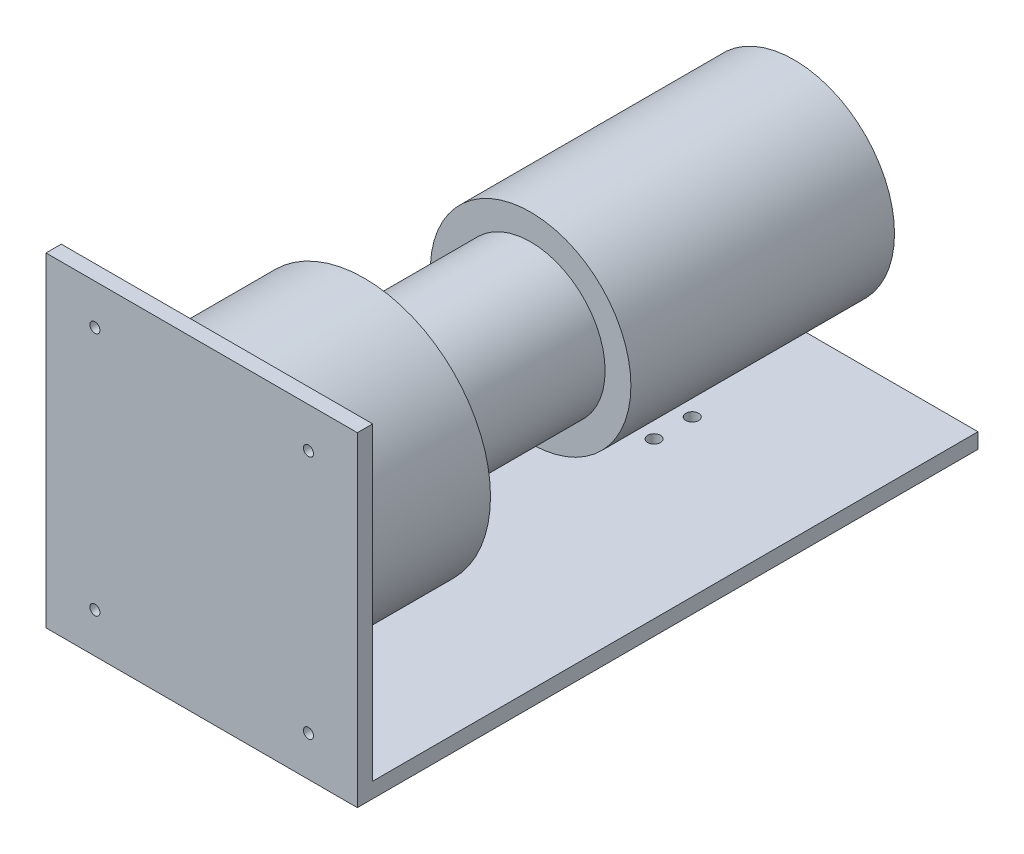
from build123d import *

# Parameters (mm, degrees)
CROQUIS1_R              = 66
SALIENTE_EXTRUIR1_DEPTH = 80
CROQUIS2_R              = 39
SALIENTE_EXTRUIR2_DEPTH = 87
CROQUIS4_R              = 52.5
SALIENTE_EXTRUIR3_DEPTH = 138
SALIENTE_EXTRUIR4_DEPTH = 81.5
CROQUIS6_R              = 2.625
CORTAR_EXTRUIR1_DEPTH   = 81.5
SKETCH1_R               = 3.35
CUT_EXTRUDE1_DEPTH      = 8


with BuildPart() as part:
    # Croquis1 → Saliente-Extruir1 (new body)
    with BuildSketch(Plane.XY):
        Circle(CROQUIS1_R)
    extrude(amount=SALIENTE_EXTRUIR1_DEPTH)

    # Croquis2 → Saliente-Extruir2 (add)
    with BuildSketch(Plane.XY):
        Circle(CROQUIS2_R)
    extrude(amount=-SALIENTE_EXTRUIR2_DEPTH)

    # Croquis4 → Saliente-Extruir3 (add)
    with BuildSketch(Plane.XY.offset(-87)):
        Circle(CROQUIS4_R)
    extrude(amount=-SALIENTE_EXTRUIR3_DEPTH)

    # Croquis5 → Saliente-Extruir4 (add, symmetric)
    with BuildSketch(Plane(origin=(0, 0, 0), x_dir=(0, 0, -1), z_dir=(1, 0, 0))):
        Polygon((-77.192193157, 79.301093587), (-85.192193157, 79.301093587), (-85.192193157, -90.698906413), (239.707949332, -90.698906413), (239.707949332, -82.698906413), (-77.192193157, -82.698906413), align=None)
    extrude(amount=SALIENTE_EXTRUIR4_DEPTH, both=True)

    # Croquis6 → Cortar-Extruir1 (cut, symmetric)
    with BuildSketch(Plane.XY.offset(85.19)):
        with Locations((-55.9, 58.301093587)):
            Circle(CROQUIS6_R)
        with Locations((55.9, 58.301093587)):
            Circle(CROQUIS6_R)
        with Locations((55.9, -69.698906413)):
            Circle(CROQUIS6_R)
        with Locations((-55.9, -69.698906413)):
            Circle(CROQUIS6_R)
    extrude(amount=CORTAR_EXTRUIR1_DEPTH, both=True, mode=Mode.SUBTRACT)

    # Sketch1 → Cut-Extrude1 (cut)
    with BuildSketch(Plane(origin=(0, -82.698906413, 0), x_dir=(1, 0, 0), z_dir=(0, 1, 0))):
        with Locations((0, 151.628034649)):
            Circle(SKETCH1_R)
        with Locations((0, 171.628034649)):
            Circle(SKETCH1_R)
    extrude(amount=-CUT_EXTRUDE1_DEPTH, mode=Mode.SUBTRACT)


solid = part.part
